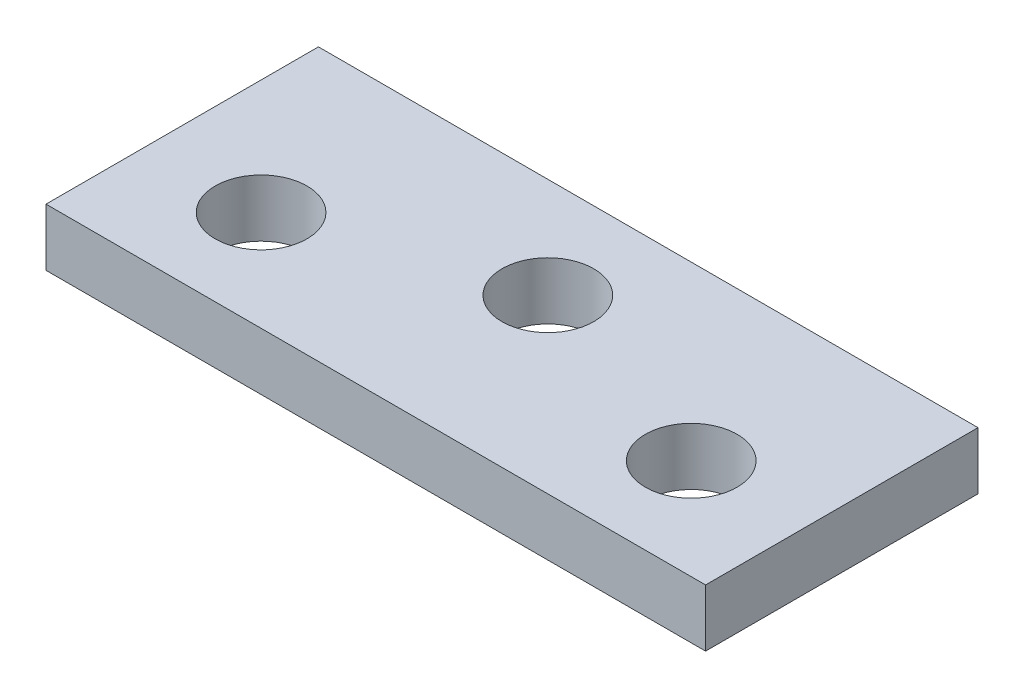
from build123d import *

# Parameters (mm, degrees)
SKETCH_1_W          = 23
SKETCH_1_H          = 9.5
EXTRUDE_1_DEPTH     = 2
SKETCH_2_R          = 1.6
CUT_EXTRUDE_1_DEPTH = 3


with BuildPart() as part:
    # 草图1 → 凸台-拉伸1 (new body)
    with BuildSketch(Plane(origin=(0, 0, 0), x_dir=(1, 0, 0), z_dir=(0, 1, 0))):
        Rectangle(SKETCH_1_W, SKETCH_1_H)
    extrude(amount=EXTRUDE_1_DEPTH)

    # 草图2 → 切除-拉伸1 (cut, through all)
    with BuildSketch(Plane(origin=(0, 2, 0), x_dir=(1, 0, 0), z_dir=(0, 1, 0))):
        with Locations((-7.5, -1.25)):
            Circle(SKETCH_2_R)
        with Locations((7.5, -1.25)):
            Circle(SKETCH_2_R)
        with Locations((0, 1.25)):
            Circle(SKETCH_2_R)
    extrude(amount=-CUT_EXTRUDE_1_DEPTH, mode=Mode.SUBTRACT)


solid = part.part
